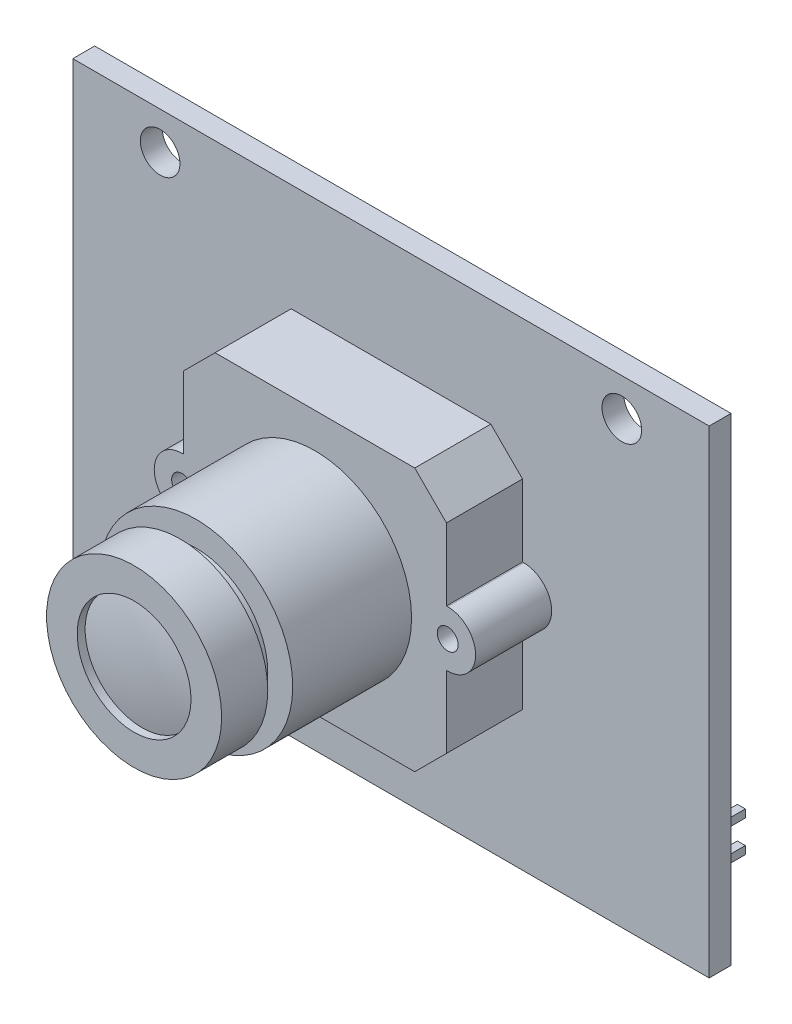
from build123d import *

# Parameters (mm, degrees)
SKETCH1_W           = 51
SKETCH1_H           = 38.31
BOSS_EXTRUDE1_DEPTH = 1.7526
SKETCH2_R           = 1.5875
CUT_EXTRUDE1_DEPTH  = 1.7526
SKETCH3_W           = 21.082
SKETCH3_H           = 21.082
BOSS_EXTRUDE2_DEPTH = 6.096
CHAMFER1_SIZE       = 2.54
BOSS_EXTRUDE4_DEPTH = 6.096
SKETCH7_R           = 0.8382
CUT_EXTRUDE2_DEPTH  = 7.8486
SKETCH4_R           = 7.747
BOSS_EXTRUDE3_DEPTH = 9.525
SKETCH8_R           = 5.74675
BOSS_EXTRUDE5_DEPTH = 1.27
SKETCH9_R           = 7.01675
BOSS_EXTRUDE6_DEPTH = 3.6957
SKETCH10_R          = 4.55988923
CUT_EXTRUDE3_DEPTH  = 0.635
DOME1_FACE_RADIUS   = 4.55988923
DOME1_HEIGHT        = 0.508
SKETCH12_W          = 2.413
SKETCH12_H          = 2.413
BOSS_EXTRUDE8_DEPTH = 1.27
SKETCH13_W          = 0.635
SKETCH13_H          = 0.635
BOSS_EXTRUDE9_DEPTH = 5.842


with BuildPart() as part:
    # Sketch1 → Boss-Extrude1 (new body)
    with BuildSketch(Plane.XY):
        with Locations((25.5, 19.155)):
            Rectangle(SKETCH1_W, SKETCH1_H)
    extrude(amount=BOSS_EXTRUDE1_DEPTH)

    # Sketch2 → Cut-Extrude1 (cut)
    with BuildSketch(Plane.XY.offset(1.7526)):
        with Locations((44, 35.31)):
            Circle(SKETCH2_R)
        with Locations((7, 35.31)):
            Circle(SKETCH2_R)
    extrude(amount=-CUT_EXTRUDE1_DEPTH, mode=Mode.SUBTRACT)

    # Sketch3 → Boss-Extrude2 (add)
    with BuildSketch(Plane.XY.offset(1.7526)):
        with Locations((25.5, 19.155)):
            Rectangle(SKETCH3_W, SKETCH3_H)
    extrude(amount=BOSS_EXTRUDE2_DEPTH)

    # Chamfer1
    chamfer1_edges = [part.edges().sort_by_distance(p)[0] for p in [
        (14.959, 29.696, 4.8006),
        (14.959, 8.614, 4.8006),
        (36.041, 8.614, 4.8006),
        (36.041, 29.696, 4.8006),
    ]]
    chamfer(chamfer1_edges, length=CHAMFER1_SIZE)

    # Sketch5 → Boss-Extrude4 (add)
    with BuildSketch(Plane.XY.offset(1.7526)):
        with BuildLine():
            Line((36.041, 21.3902), (36.1426, 21.3902))
            ThreePointArc((36.1426, 21.3902), (38.3778, 19.155), (36.1426, 16.9198))
            Line((36.1426, 16.9198), (36.041, 16.9198))
            Line((36.041, 16.9198), (36.041, 21.3902))
        make_face()
        with BuildLine():
            Line((14.8574, 21.3902), (14.959, 21.3902))
            Line((14.959, 21.3902), (14.959, 16.9198))
            Line((14.959, 16.9198), (14.8574, 16.9198))
            ThreePointArc((14.8574, 16.9198), (12.6222, 19.155), (14.8574, 21.3902))
        make_face()
    extrude(amount=BOSS_EXTRUDE4_DEPTH)

    # Sketch7 → Cut-Extrude2 (cut)
    with BuildSketch(Plane.XY.offset(7.8486)):
        with Locations((14.8574, 19.155)):
            Circle(SKETCH7_R)
        with Locations((36.1426, 19.155)):
            Circle(SKETCH7_R)
    extrude(amount=-CUT_EXTRUDE2_DEPTH, mode=Mode.SUBTRACT)

    # Sketch4 → Boss-Extrude3 (add)
    with BuildSketch(Plane.XY.offset(7.8486)):
        with Locations((25.5, 19.155)):
            Circle(SKETCH4_R)
    extrude(amount=BOSS_EXTRUDE3_DEPTH)

    # Sketch8 → Boss-Extrude5 (add)
    with BuildSketch(Plane.XY.offset(17.3736)):
        with Locations((25.5, 19.155)):
            Circle(SKETCH8_R)
    extrude(amount=BOSS_EXTRUDE5_DEPTH)

    # Sketch9 → Boss-Extrude6 (add)
    with BuildSketch(Plane.XY.offset(18.6436)):
        with Locations((25.5, 19.155)):
            Circle(SKETCH9_R)
    extrude(amount=BOSS_EXTRUDE6_DEPTH)

    # Sketch10 → Cut-Extrude3 (cut)
    with BuildSketch(Plane.XY.offset(22.3393)):
        with Locations((25.5, 19.155)):
            Circle(SKETCH10_R)
    extrude(amount=-CUT_EXTRUDE3_DEPTH, mode=Mode.SUBTRACT)

    # Dome1: a dome of height H over a round flat face of radius A is a cap of a sphere of radius (A * A + H * H) / (2 * H)
    dome1_r = (DOME1_FACE_RADIUS * DOME1_FACE_RADIUS + DOME1_HEIGHT * DOME1_HEIGHT) / (2 * DOME1_HEIGHT)
    dome1_base = Plane((25.5, 19.155, 21.7043), z_dir=(0, 0, 1))
    with Locations(dome1_base.offset(DOME1_HEIGHT - dome1_r)):
        dome1_ball = Sphere(dome1_r, mode=Mode.PRIVATE)
    add(split(dome1_ball, bisect_by=dome1_base, keep=Keep.TOP, mode=Mode.PRIVATE))

    # Sketch12 → Boss-Extrude8 (add)
    with BuildSketch(Plane(origin=(0, 0, 0), x_dir=(-1, 0, 0), z_dir=(0, 0, -1))):
        with Locations((-44.7135, 1.4605)):
            Rectangle(SKETCH12_W, SKETCH12_H)
        with Locations((-42.1735, 1.4605)):
            Rectangle(SKETCH12_W, SKETCH12_H)
        with Locations((-39.6335, 1.4605)):
            Rectangle(SKETCH12_W, SKETCH12_H)
        with Locations((-37.0935, 1.4605)):
            Rectangle(SKETCH12_W, SKETCH12_H)
        with Locations((-34.5535, 1.4605)):
            Rectangle(SKETCH12_W, SKETCH12_H)
        with Locations((-32.0135, 1.4605)):
            Rectangle(SKETCH12_W, SKETCH12_H)
        with Locations((-29.4735, 1.4605)):
            Rectangle(SKETCH12_W, SKETCH12_H)
        with Locations((-26.9335, 1.4605)):
            Rectangle(SKETCH12_W, SKETCH12_H)
        with Locations((-24.3935, 1.4605)):
            Rectangle(SKETCH12_W, SKETCH12_H)
        with Locations((-21.8535, 1.4605)):
            Rectangle(SKETCH12_W, SKETCH12_H)
        with Locations((-19.3135, 1.4605)):
            Rectangle(SKETCH12_W, SKETCH12_H)
        with Locations((-16.7735, 1.4605)):
            Rectangle(SKETCH12_W, SKETCH12_H)
        with Locations((-14.2335, 1.4605)):
            Rectangle(SKETCH12_W, SKETCH12_H)
        with Locations((-11.6935, 1.4605)):
            Rectangle(SKETCH12_W, SKETCH12_H)
        with Locations((-9.1535, 1.4605)):
            Rectangle(SKETCH12_W, SKETCH12_H)
        with Locations((-6.6135, 1.4605)):
            Rectangle(SKETCH12_W, SKETCH12_H)
        with Locations((-42.1735, 4.0005)):
            Rectangle(SKETCH12_W, SKETCH12_H)
        with Locations((-39.6335, 4.0005)):
            Rectangle(SKETCH12_W, SKETCH12_H)
        with Locations((-37.0935, 4.0005)):
            Rectangle(SKETCH12_W, SKETCH12_H)
        with Locations((-34.5535, 4.0005)):
            Rectangle(SKETCH12_W, SKETCH12_H)
        with Locations((-32.0135, 4.0005)):
            Rectangle(SKETCH12_W, SKETCH12_H)
        with Locations((-29.4735, 4.0005)):
            Rectangle(SKETCH12_W, SKETCH12_H)
        with Locations((-26.9335, 4.0005)):
            Rectangle(SKETCH12_W, SKETCH12_H)
        with Locations((-24.3935, 4.0005)):
            Rectangle(SKETCH12_W, SKETCH12_H)
        with Locations((-21.8535, 4.0005)):
            Rectangle(SKETCH12_W, SKETCH12_H)
        with Locations((-19.3135, 4.0005)):
            Rectangle(SKETCH12_W, SKETCH12_H)
        with Locations((-16.7735, 4.0005)):
            Rectangle(SKETCH12_W, SKETCH12_H)
        with Locations((-14.2335, 4.0005)):
            Rectangle(SKETCH12_W, SKETCH12_H)
        with Locations((-11.6935, 4.0005)):
            Rectangle(SKETCH12_W, SKETCH12_H)
        with Locations((-9.1535, 4.0005)):
            Rectangle(SKETCH12_W, SKETCH12_H)
        with Locations((-6.6135, 4.0005)):
            Rectangle(SKETCH12_W, SKETCH12_H)
        with Locations((-44.7135, 4.0005)):
            Rectangle(SKETCH12_W, SKETCH12_H)
    extrude(amount=BOSS_EXTRUDE8_DEPTH)

    # Sketch13 → Boss-Extrude9 (add)
    with BuildSketch(Plane(origin=(0, 0, -1.27), x_dir=(-1, 0, 0), z_dir=(0, 0, -1))):
        with Locations((-42.1735, 1.4605)):
            Rectangle(SKETCH13_W, SKETCH13_H)
        with Locations((-44.7135, 1.4605)):
            Rectangle(SKETCH13_W, SKETCH13_H)
        with Locations((-39.6335, 1.4605)):
            Rectangle(SKETCH13_W, SKETCH13_H)
        with Locations((-37.0935, 1.4605)):
            Rectangle(SKETCH13_W, SKETCH13_H)
        with Locations((-34.5535, 1.4605)):
            Rectangle(SKETCH13_W, SKETCH13_H)
        with Locations((-32.0135, 1.4605)):
            Rectangle(SKETCH13_W, SKETCH13_H)
        with Locations((-29.4735, 1.4605)):
            Rectangle(SKETCH13_W, SKETCH13_H)
        with Locations((-26.9335, 1.4605)):
            Rectangle(SKETCH13_W, SKETCH13_H)
        with Locations((-24.3935, 1.4605)):
            Rectangle(SKETCH13_W, SKETCH13_H)
        with Locations((-21.8535, 1.4605)):
            Rectangle(SKETCH13_W, SKETCH13_H)
        with Locations((-19.3135, 1.4605)):
            Rectangle(SKETCH13_W, SKETCH13_H)
        with Locations((-16.7735, 1.4605)):
            Rectangle(SKETCH13_W, SKETCH13_H)
        with Locations((-14.2335, 1.4605)):
            Rectangle(SKETCH13_W, SKETCH13_H)
        with Locations((-11.6935, 1.4605)):
            Rectangle(SKETCH13_W, SKETCH13_H)
        with Locations((-9.1535, 1.4605)):
            Rectangle(SKETCH13_W, SKETCH13_H)
        with Locations((-6.6135, 1.4605)):
            Rectangle(SKETCH13_W, SKETCH13_H)
        with Locations((-42.1735, 4.0005)):
            Rectangle(SKETCH13_W, SKETCH13_H)
        with Locations((-39.6335, 4.0005)):
            Rectangle(SKETCH13_W, SKETCH13_H)
        with Locations((-37.0935, 4.0005)):
            Rectangle(SKETCH13_W, SKETCH13_H)
        with Locations((-34.5535, 4.0005)):
            Rectangle(SKETCH13_W, SKETCH13_H)
        with Locations((-32.0135, 4.0005)):
            Rectangle(SKETCH13_W, SKETCH13_H)
        with Locations((-29.4735, 4.0005)):
            Rectangle(SKETCH13_W, SKETCH13_H)
        with Locations((-26.9335, 4.0005)):
            Rectangle(SKETCH13_W, SKETCH13_H)
        with Locations((-24.3935, 4.0005)):
            Rectangle(SKETCH13_W, SKETCH13_H)
        with Locations((-21.8535, 4.0005)):
            Rectangle(SKETCH13_W, SKETCH13_H)
        with Locations((-19.3135, 4.0005)):
            Rectangle(SKETCH13_W, SKETCH13_H)
        with Locations((-16.7735, 4.0005)):
            Rectangle(SKETCH13_W, SKETCH13_H)
        with Locations((-14.2335, 4.0005)):
            Rectangle(SKETCH13_W, SKETCH13_H)
        with Locations((-11.6935, 4.0005)):
            Rectangle(SKETCH13_W, SKETCH13_H)
        with Locations((-9.1535, 4.0005)):
            Rectangle(SKETCH13_W, SKETCH13_H)
        with Locations((-6.6135, 4.0005)):
            Rectangle(SKETCH13_W, SKETCH13_H)
        with Locations((-44.7135, 4.0005)):
            Rectangle(SKETCH13_W, SKETCH13_H)
    extrude(amount=BOSS_EXTRUDE9_DEPTH)


solid = part.part
